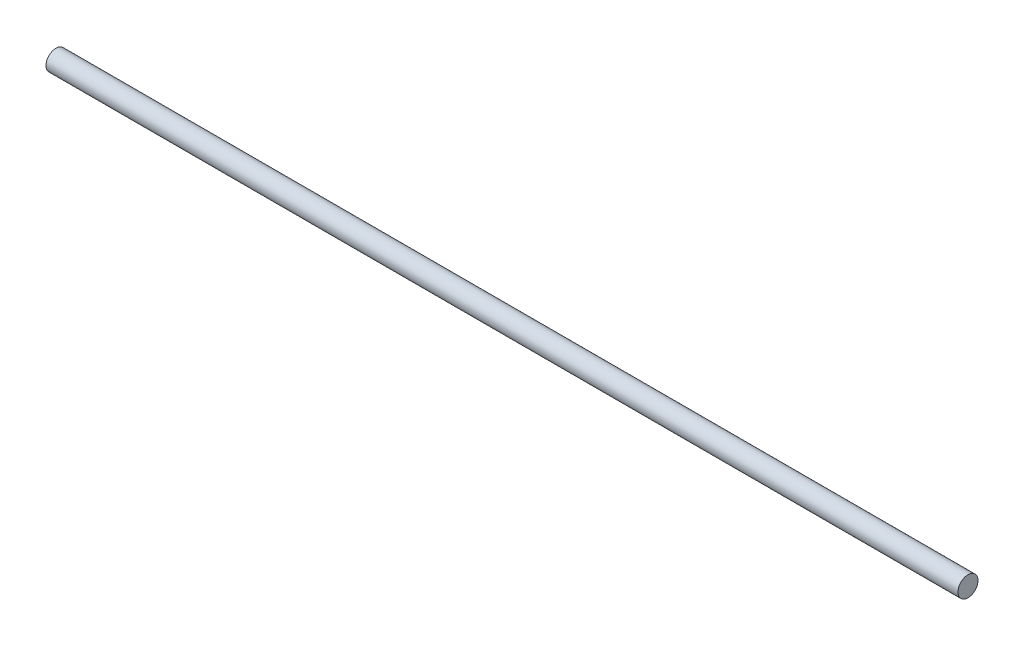
from build123d import *

# Parameters (mm, degrees)
SKETCH1_R           = 1.5875
BOSS_EXTRUDE1_DEPTH = 72.3011


with BuildPart() as part:
    # Sketch1 → Boss-Extrude1 (new body, symmetric)
    with BuildSketch(Plane(origin=(0, 0, 0), x_dir=(0, 0, -1), z_dir=(1, 0, 0))):
        Circle(SKETCH1_R)
    extrude(amount=BOSS_EXTRUDE1_DEPTH, both=True)


solid = part.part
